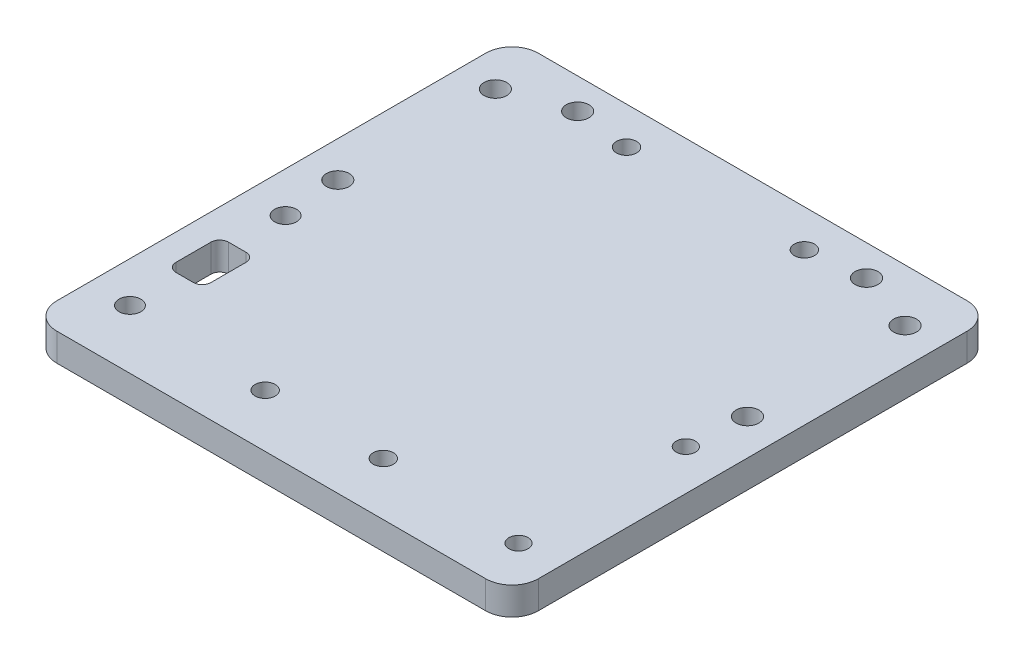
from build123d import *

# Parameters (mm, degrees)
SKETCH1_W           = 55
SKETCH1_H           = 55
BOSS_EXTRUDE1_DEPTH = 3.175
SKETCH2_R           = 1.3
CUT_EXTRUDE1_DEPTH  = 3.175
FILLET1_R           = 3
SKETCH3_R           = 1.25
SKETCH3_R_2         = 1.1
CUT_EXTRUDE2_DEPTH  = 3.175
SKETCH4_R           = 1.15
CUT_EXTRUDE3_DEPTH  = 3.175
SKETCH5_R           = 1.15
CUT_EXTRUDE4_DEPTH  = 3.175
SKETCH6_R           = 1.3
CUT_EXTRUDE5_DEPTH  = 3.175
CUT_EXTRUDE6_DEPTH  = 3.175


with BuildPart() as part:
    # Sketch1 → Boss-Extrude1 (new body)
    with BuildSketch(Plane(origin=(0, 0, 0), x_dir=(1, 0, 0), z_dir=(0, 1, 0))):
        Rectangle(SKETCH1_W, SKETCH1_H)
    extrude(amount=BOSS_EXTRUDE1_DEPTH)

    # Sketch2 → Cut-Extrude1 (cut)
    with BuildSketch(Plane(origin=(0, 3.175, 0), x_dir=(1, 0, 0), z_dir=(0, 1, 0))):
        with Locations((-23.4, 21.5)):
            Circle(SKETCH2_R)
        with Locations((-23.4, 3.5)):
            Circle(SKETCH2_R)
        with Locations((23.4, 3.5)):
            Circle(SKETCH2_R)
        with Locations((23.4, 21.5)):
            Circle(SKETCH2_R)
    extrude(amount=-CUT_EXTRUDE1_DEPTH, mode=Mode.SUBTRACT)

    # Fillet1
    fillet1_edges = [part.edges().sort_by_distance(p)[0] for p in [
        (27.5, 1.5875, 27.5),
        (-27.5, 1.5875, 27.5),
        (-27.5, 1.5875, -27.5),
        (27.5, 1.5875, -27.5),
    ]]
    fillet(fillet1_edges, radius=FILLET1_R)

    # Sketch3 → Cut-Extrude2 (cut)
    with BuildSketch(Plane(origin=(0, 3.175, 0), x_dir=(1, 0, 0), z_dir=(0, 1, 0))):
        with Locations((-22.865, -3)):
            Circle(SKETCH3_R)
        with Locations((22.855, -3)):
            Circle(SKETCH3_R_2)
        with Locations((22.855, -22.11)):
            Circle(SKETCH3_R_2)
        with Locations((-22.865, -20.78)):
            Circle(SKETCH3_R)
    extrude(amount=-CUT_EXTRUDE2_DEPTH, mode=Mode.SUBTRACT)

    # Sketch4 → Cut-Extrude3 (cut)
    with BuildSketch(Plane(origin=(0, 3.175, 0), x_dir=(1, 0, 0), z_dir=(0, 1, 0))):
        with Locations((-10.16, 23.24)):
            Circle(SKETCH4_R)
        with Locations((10.16, 23.24)):
            Circle(SKETCH4_R)
    extrude(amount=-CUT_EXTRUDE3_DEPTH, mode=Mode.SUBTRACT)

    # Sketch5 → Cut-Extrude4 (cut)
    with BuildSketch(Plane(origin=(0, 3.175, 0), x_dir=(1, 0, 0), z_dir=(0, 1, 0))):
        with Locations((-6.75, -21.45)):
            Circle(SKETCH5_R)
        with Locations((6.75, -21.45)):
            Circle(SKETCH5_R)
    extrude(amount=-CUT_EXTRUDE4_DEPTH, mode=Mode.SUBTRACT)

    # Sketch6 → Cut-Extrude5 (cut)
    with BuildSketch(Plane(origin=(0, 3.175, 0), x_dir=(1, 0, 0), z_dir=(0, 1, 0))):
        with Locations((-16.5, 24)):
            Circle(SKETCH6_R)
        with Locations((16.5, 24)):
            Circle(SKETCH6_R)
    extrude(amount=-CUT_EXTRUDE5_DEPTH, mode=Mode.SUBTRACT)

    # Sketch7 → Cut-Extrude6 (cut)
    with BuildSketch(Plane(origin=(0, 3.175, 0), x_dir=(1, 0, 0), z_dir=(0, 1, 0))):
        with BuildLine():
            Line((-23.5, -8.89), (-21.5, -8.89))
            ThreePointArc((-21.5, -8.89), (-20.792893219, -9.182893219), (-20.5, -9.89))
            Line((-20.5, -9.89), (-20.5, -13.89))
            ThreePointArc((-20.5, -13.89), (-20.792893219, -14.597106781), (-21.5, -14.89))
            Line((-21.5, -14.89), (-23.5, -14.89))
            ThreePointArc((-23.5, -14.89), (-24.207106781, -14.597106781), (-24.5, -13.89))
            Line((-24.5, -13.89), (-24.5, -9.89))
            ThreePointArc((-24.5, -9.89), (-24.207106781, -9.182893219), (-23.5, -8.89))
        make_face()
    extrude(amount=-CUT_EXTRUDE6_DEPTH, mode=Mode.SUBTRACT)


solid = part.part
